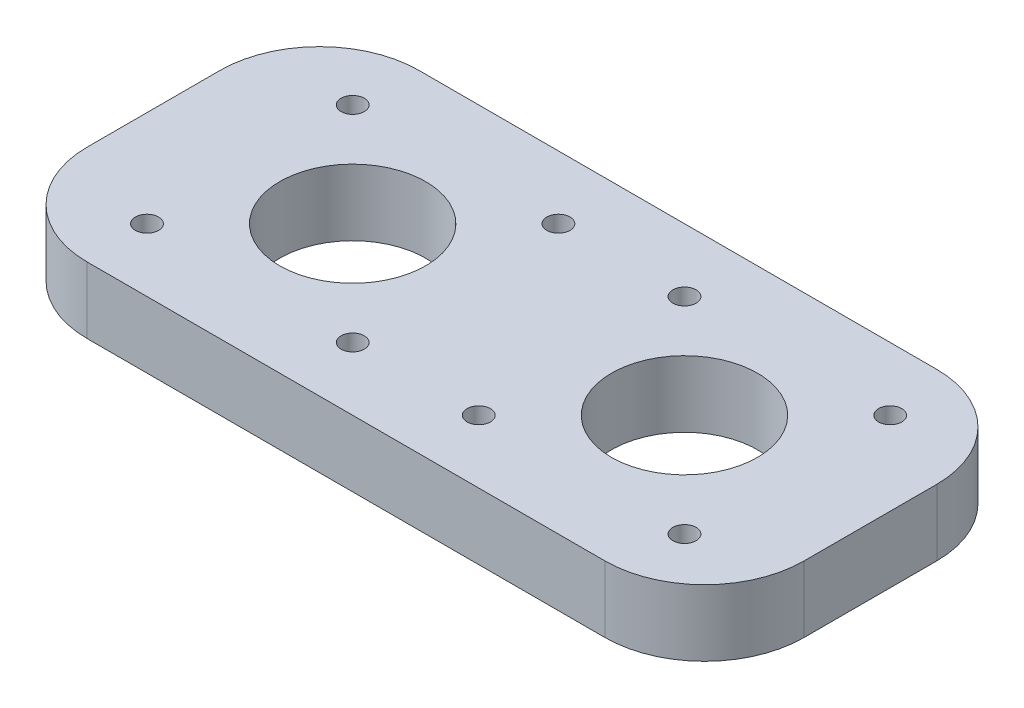
from build123d import *

# Parameters (mm, degrees)
SKETCH1_W           = 108.016753786
SKETCH1_H           = 50
SKETCH1_R           = 11
SKETCH1_R_2         = 1.75
BOSS_EXTRUDE1_DEPTH = 10
FILLET1_R           = 15


with BuildPart() as part:
    # Sketch1 → Boss-Extrude1 (new body)
    with BuildSketch(Plane(origin=(0, 0, 0), x_dir=(1, 0, 0), z_dir=(0, 1, 0))):
        with Locations((-25.991623107, 0)):
            Rectangle(SKETCH1_W, SKETCH1_H)
        Circle(SKETCH1_R, mode=Mode.SUBTRACT)
        with Locations((15.5, 15.5)):
            Circle(SKETCH1_R_2, mode=Mode.SUBTRACT)
        with Locations((-15.5, 15.5)):
            Circle(SKETCH1_R_2, mode=Mode.SUBTRACT)
        with Locations((-15.5, -15.5)):
            Circle(SKETCH1_R_2, mode=Mode.SUBTRACT)
        with Locations((15.5, -15.5)):
            Circle(SKETCH1_R_2, mode=Mode.SUBTRACT)
        with Locations((-65.5, 15.5)):
            Circle(SKETCH1_R_2, mode=Mode.SUBTRACT)
        with Locations((-34.5, 15.5)):
            Circle(SKETCH1_R_2, mode=Mode.SUBTRACT)
        with Locations((-34.5, -15.5)):
            Circle(SKETCH1_R_2, mode=Mode.SUBTRACT)
        with Locations((-65.5, -15.5)):
            Circle(SKETCH1_R_2, mode=Mode.SUBTRACT)
        with Locations((-50, 0)):
            Circle(SKETCH1_R, mode=Mode.SUBTRACT)
    extrude(amount=BOSS_EXTRUDE1_DEPTH)

    # Fillet1
    fillet1_edges = [part.edges().sort_by_distance(p)[0] for p in [
        (-80, 5, -25),
        (28.016753786, 5, -25),
        (28.016753786, 5, 25),
        (-80, 5, 25),
    ]]
    fillet(fillet1_edges, radius=FILLET1_R)


solid = part.part
